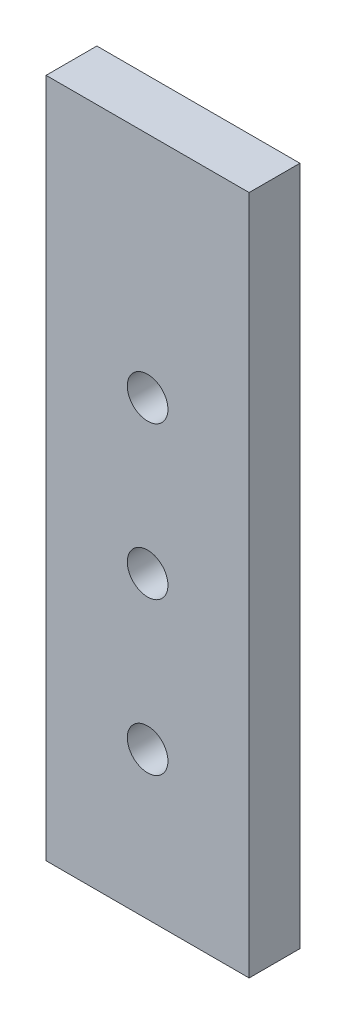
from build123d import *

# Parameters (mm, degrees)
SKETCH1_W           = 20
SKETCH1_H           = 30
BOSS_EXTRUDE1_DEPTH = 5
SKETCH2_R           = 2
CUT_EXTRUDE1_DEPTH  = 5
SKETCH3_W           = 20
SKETCH3_H           = 5
BOSS_EXTRUDE2_DEPTH = 7
SKETCH4_W           = 20
SKETCH4_H           = 5
BOSS_EXTRUDE3_DEPTH = 30
SKETCH5_R           = 2
CUT_EXTRUDE2_DEPTH  = 7


with BuildPart() as part:
    # Sketch1 → Boss-Extrude1 (new body)
    with BuildSketch(Plane.XY):
        Rectangle(SKETCH1_W, SKETCH1_H)
    extrude(amount=BOSS_EXTRUDE1_DEPTH)

    # Sketch2 → Cut-Extrude1 (cut)
    with BuildSketch(Plane.XY.offset(5)):
        with Locations((0, 7.5)):
            Circle(SKETCH2_R)
        with Locations((0, -7.5)):
            Circle(SKETCH2_R)
    extrude(amount=-CUT_EXTRUDE1_DEPTH, mode=Mode.SUBTRACT)

    # Sketch3 → Boss-Extrude2 (add)
    with BuildSketch(Plane.XZ.offset(15)):
        with Locations((0, 2.5)):
            Rectangle(SKETCH3_W, SKETCH3_H)
    extrude(amount=BOSS_EXTRUDE2_DEPTH)

    # Sketch4 → Boss-Extrude3 (add)
    with BuildSketch(Plane(origin=(0, 15, 0), x_dir=(1, 0, 0), z_dir=(0, 1, 0))):
        with Locations((0, -2.5)):
            Rectangle(SKETCH4_W, SKETCH4_H)
    extrude(amount=BOSS_EXTRUDE3_DEPTH)

    # Sketch5 → Cut-Extrude2 (cut)
    with BuildSketch(Plane(origin=(0, 0, 0), x_dir=(-1, 0, 0), z_dir=(0, 0, -1))):
        with Locations((0, 22.5)):
            Circle(SKETCH5_R)
    extrude(amount=-CUT_EXTRUDE2_DEPTH, mode=Mode.SUBTRACT)


solid = part.part
